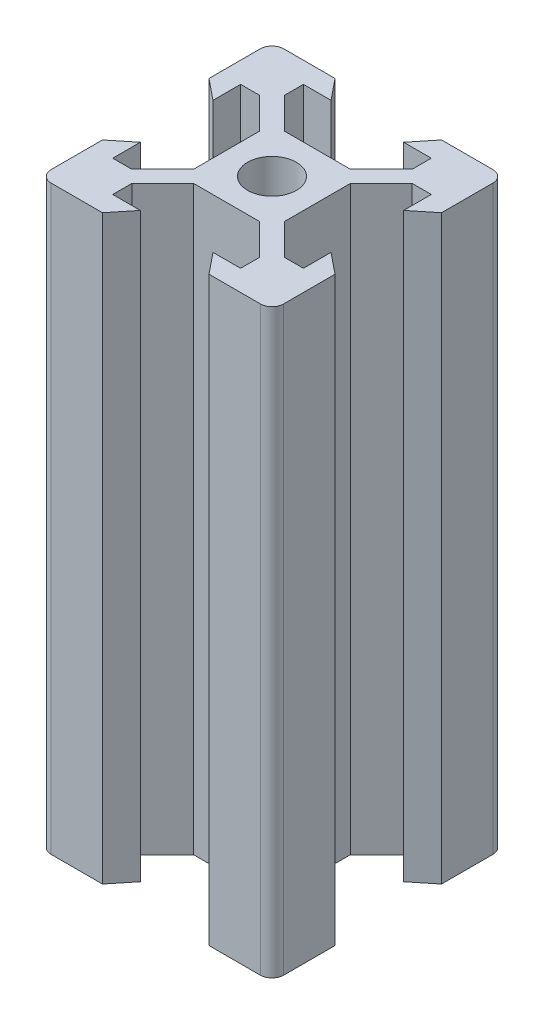
from build123d import *

# Parameters (mm, degrees)
SKETCH1_R           = 2.1
BOSS_EXTRUDE1_DEPTH = 50


with BuildPart() as part:
    # Sketch1 → Boss-Extrude1 (new body)
    with BuildSketch(Plane(origin=(0, 0, 0), x_dir=(1, 0, 0), z_dir=(0, 1, 0))):
        with BuildLine():
            Line((-5.5, 8.2), (-3.125, 8.2))
            Line((-3.125, 8.2), (-4.58, 10))
            Line((-4.58, 10), (-9, 10))
            ThreePointArc((-9, 10), (-9.707106781, 9.707106781), (-10, 9))
            Line((-10, 9), (-10, 4.58))
            Line((-10, 4.58), (-8.2, 3.125))
            Line((-8.2, 3.125), (-8.2, 5.5))
            Line((-8.2, 5.5), (-6.56, 5.5))
            Line((-6.56, 5.5), (-3.9, 2.84))
            Line((-3.9, 2.84), (-3.9, -2.84))
            Line((-3.9, -2.84), (-6.56, -5.5))
            Line((-6.56, -5.5), (-8.2, -5.5))
            Line((-8.2, -5.5), (-8.2, -3.125))
            Line((-8.2, -3.125), (-10, -4.58))
            Line((-10, -4.58), (-10, -9))
            ThreePointArc((-10, -9), (-9.707106781, -9.707106781), (-9, -10))
            Line((-9, -10), (-4.58, -10))
            Line((-4.58, -10), (-3.125, -8.2))
            Line((-3.125, -8.2), (-5.5, -8.2))
            Line((-5.5, -8.2), (-5.5, -6.56))
            Line((-5.5, -6.56), (-2.84, -3.9))
            Line((-2.84, -3.9), (2.84, -3.9))
            Line((2.84, -3.9), (5.5, -6.56))
            Line((5.5, -6.56), (5.5, -8.2))
            Line((5.5, -8.2), (3.125, -8.2))
            Line((3.125, -8.2), (4.58, -10))
            Line((4.58, -10), (9, -10))
            ThreePointArc((9, -10), (9.707106781, -9.707106781), (10, -9))
            Line((10, -9), (10, -4.58))
            Line((10, -4.58), (8.2, -3.125))
            Line((8.2, -3.125), (8.2, -5.5))
            Line((8.2, -5.5), (6.56, -5.5))
            Line((6.56, -5.5), (3.9, -2.84))
            Line((3.9, -2.84), (3.9, 2.84))
            Line((3.9, 2.84), (6.56, 5.5))
            Line((6.56, 5.5), (8.2, 5.5))
            Line((8.2, 5.5), (8.2, 3.125))
            Line((8.2, 3.125), (10, 4.58))
            Line((10, 4.58), (10, 9))
            ThreePointArc((10, 9), (9.707106781, 9.707106781), (9, 10))
            Line((9, 10), (4.58, 10))
            Line((4.58, 10), (3.125, 8.2))
            Line((3.125, 8.2), (5.5, 8.2))
            Line((5.5, 8.2), (5.5, 6.56))
            Line((5.5, 6.56), (2.84, 3.9))
            Line((2.84, 3.9), (-2.84, 3.9))
            Line((-2.84, 3.9), (-5.5, 6.56))
            Line((-5.5, 6.56), (-5.5, 8.2))
        make_face()
        Circle(SKETCH1_R, mode=Mode.SUBTRACT)
    extrude(amount=BOSS_EXTRUDE1_DEPTH)


solid = part.part
